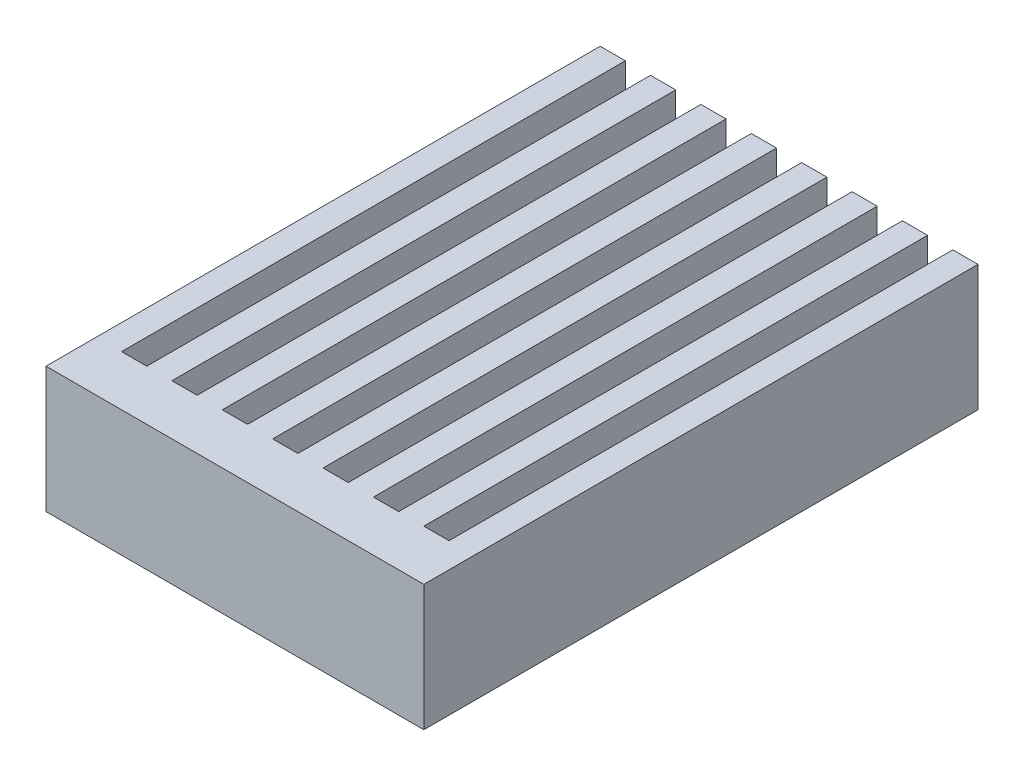
from build123d import *

# Parameters (mm, degrees)
SKETCH1_W           = 15
SKETCH1_H           = 2
BOSS_EXTRUDE1_DEPTH = 5
SKETCH1_3_W         = 1
SKETCH1_3_H         = 20
BOSS_EXTRUDE2_DEPTH = 5
LPATTERN1_COUNT     = 8
LPATTERN1_PITCH     = 2


with BuildPart() as part:
    # Sketch1 → Boss-Extrude1 (new body)
    with BuildSketch(Plane(origin=(0, 0, 0), x_dir=(1, 0, 0), z_dir=(0, 1, 0))):
        with Locations((1.806666667, -1.313333333)):
            Rectangle(SKETCH1_W, SKETCH1_H)
    extrude(amount=BOSS_EXTRUDE1_DEPTH)

    # Sketch1_3 → Boss-Extrude2 (add)
    with BuildSketch(Plane(origin=(0, 0, 0), x_dir=(1, 0, 0), z_dir=(0, 1, 0))):
        with Locations((-5.193333333, 9.686666667)):
            Rectangle(SKETCH1_3_W, SKETCH1_3_H)
    boss_extrude2 = extrude(amount=BOSS_EXTRUDE2_DEPTH)

    # LPattern1: Boss-Extrude2 ×8
    with Locations(*[(i * LPATTERN1_PITCH, 0, 0) for i in range(1, LPATTERN1_COUNT)]):
        add(boss_extrude2)


solid = part.part
